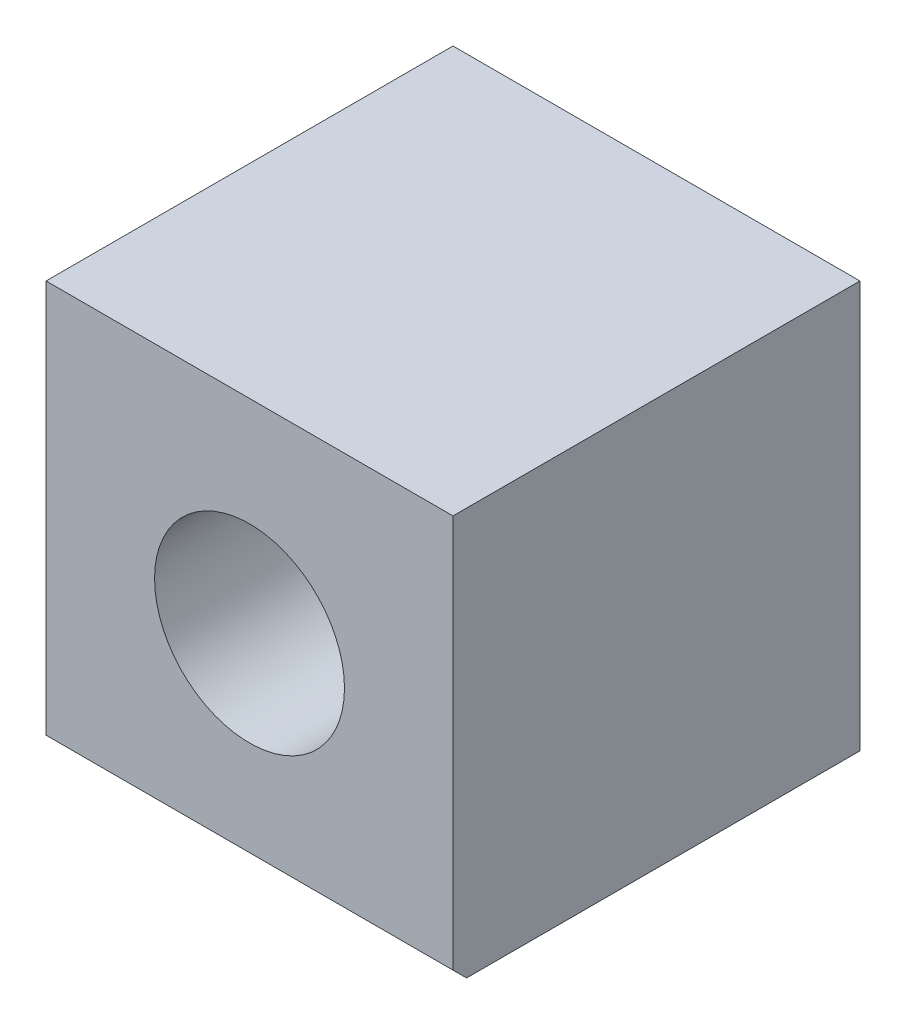
from build123d import *

# Parameters (mm, degrees)
SKETCH_1_W          = 6
SKETCH_1_H          = 6
EXTRUDE_1_DEPTH     = 6
SKETCH_2_R          = 1.4
CUT_EXTRUDE_1_DEPTH = 7
CUT_EXTRUDE_2_DEPTH = 7


with BuildPart() as part:
    # ｽｹｯﾁ1 → ﾎﾞｽ - 押し出し1 (new body)
    with BuildSketch(Plane.XY):
        with Locations((0.221154353, -0.1069869)):
            Rectangle(SKETCH_1_W, SKETCH_1_H)
    extrude(amount=EXTRUDE_1_DEPTH)

    # ｽｹｯﾁ2 → ｶｯﾄ - 押し出し1 (cut, through all)
    with BuildSketch(Plane.XY.offset(6)):
        with Locations((0.221154353, -0.1069869)):
            Circle(SKETCH_2_R)
    extrude(amount=-CUT_EXTRUDE_1_DEPTH, mode=Mode.SUBTRACT)

    # ｽｹｯﾁ3 → ｶｯﾄ - 押し出し2 (cut, through all)
    with BuildSketch(Plane(origin=(3.221154353, 0, 0), x_dir=(0, 0, -1), z_dir=(1, 0, 0))):
        Polygon((-6, -3.1069869), (-6, -2.9069869), (-5.8, -3.1069869), align=None)
    extrude(amount=-CUT_EXTRUDE_2_DEPTH, mode=Mode.SUBTRACT)


solid = part.part
